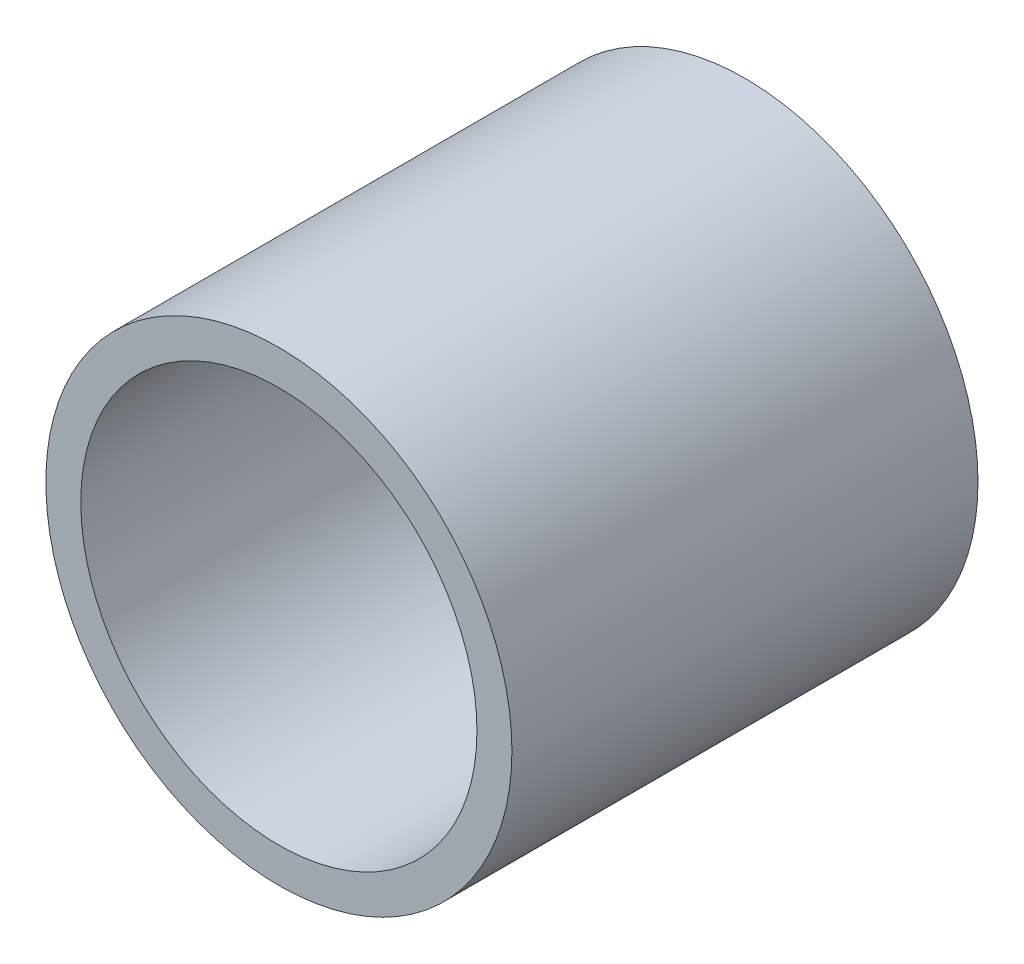
from build123d import *

# Parameters (mm, degrees)
SKETCH_1_R          = 20
EXTRUDE_1_DEPTH     = 40
SKETCH_2_R          = 17
CUT_EXTRUDE_1_DEPTH = 37


with BuildPart() as part:
    # 草图1 → 凸台-拉伸1 (new body)
    with BuildSketch(Plane.XY):
        with Locations((-4.524818577, 16.887269333)):
            Circle(SKETCH_1_R)
    extrude(amount=EXTRUDE_1_DEPTH)

    # 草图2 → 切除-拉伸1 (cut)
    with BuildSketch(Plane.XY.offset(40)):
        with Locations((-4.524818577, 16.887269333)):
            Circle(SKETCH_2_R)
    extrude(amount=-CUT_EXTRUDE_1_DEPTH, mode=Mode.SUBTRACT)


solid = part.part
